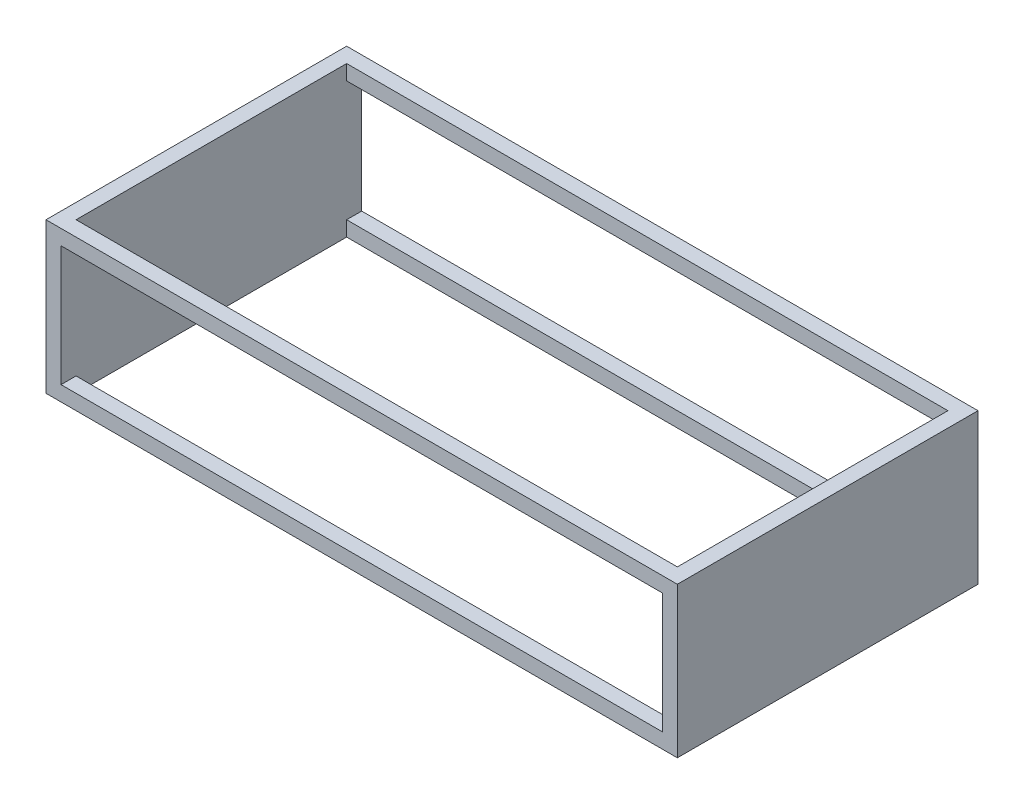
from build123d import *

# Parameters (mm, degrees)
SKETCH1_W           = 2100
SKETCH1_H           = 1000
BOSS_EXTRUDE1_DEPTH = 250
CUT_EXTRUDE1_REACH  = 502
SKETCH2_W           = 2000
SKETCH2_H           = 900
SKETCH3_W           = 2000
SKETCH3_H           = 400
CUT_EXTRUDE2_DEPTH  = 1206


with BuildPart() as part:
    # Sketch1 → Boss-Extrude1 (new body, symmetric)
    with BuildSketch(Plane(origin=(0, 0, 0), x_dir=(1, 0, 0), z_dir=(0, 1, 0))):
        Rectangle(SKETCH1_W, SKETCH1_H)
    extrude(amount=BOSS_EXTRUDE1_DEPTH, both=True)

    # Sketch2 → Cut-Extrude1 (cut, up to next)
    with BuildSketch(Plane(origin=(0, 250, 0), x_dir=(1, 0, 0), z_dir=(0, 1, 0)), mode=Mode.PRIVATE) as cut_extrude1_sk1:
        Rectangle(SKETCH2_W, SKETCH2_H)
    cut_extrude1_tool1 = extrude(cut_extrude1_sk1.sketch, amount=-CUT_EXTRUDE1_REACH, mode=Mode.PRIVATE) & part.part
    add(cut_extrude1_tool1.solids().sort_by_distance((0, 250, 0))[0], mode=Mode.SUBTRACT)

    # Sketch3 → Cut-Extrude2 (cut)
    with BuildSketch(Plane(origin=(0, 0, -500), x_dir=(-1, 0, 0), z_dir=(0, 0, -1))):
        Rectangle(SKETCH3_W, SKETCH3_H)
    extrude(amount=-CUT_EXTRUDE2_DEPTH, mode=Mode.SUBTRACT)


solid = part.part
